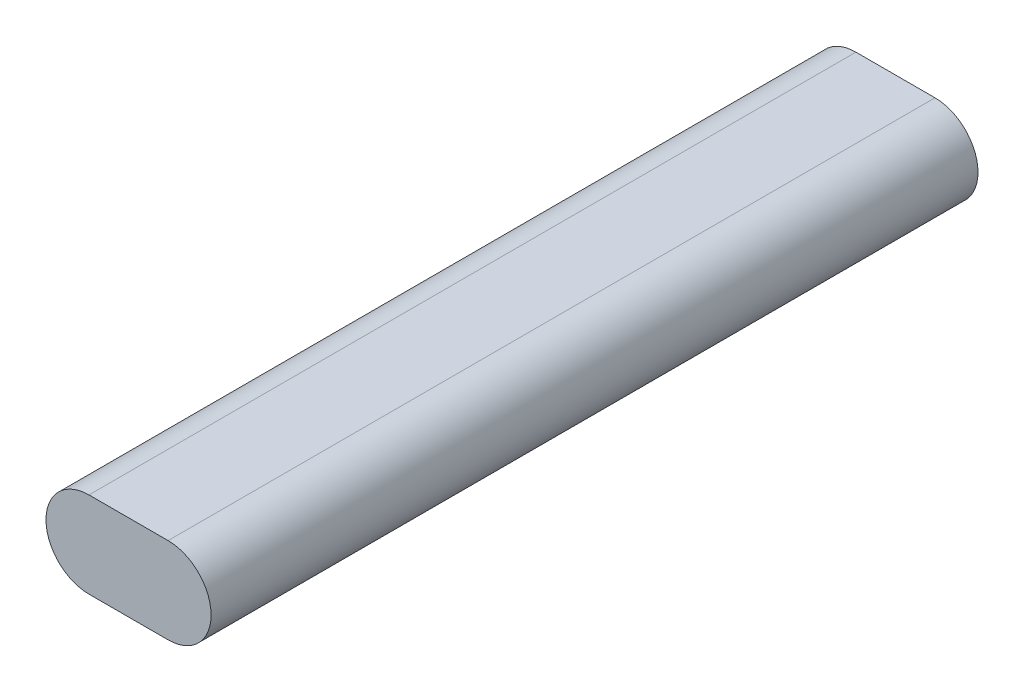
from build123d import *

# Parameters (mm, degrees)
BOSS_EXTRUDE1_DEPTH = 223


with BuildPart() as part:
    # Sketch1 → Boss-Extrude1 (new body)
    with BuildSketch(Plane.XY):
        with BuildLine():
            Line((-11.5, 12.5), (11.5, 12.5))
            ThreePointArc((11.5, 12.5), (24, 0), (11.5, -12.5))
            Line((11.5, -12.5), (-11.5, -12.5))
            ThreePointArc((-11.5, -12.5), (-24, 0), (-11.5, 12.5))
        make_face()
    extrude(amount=BOSS_EXTRUDE1_DEPTH)


solid = part.part
